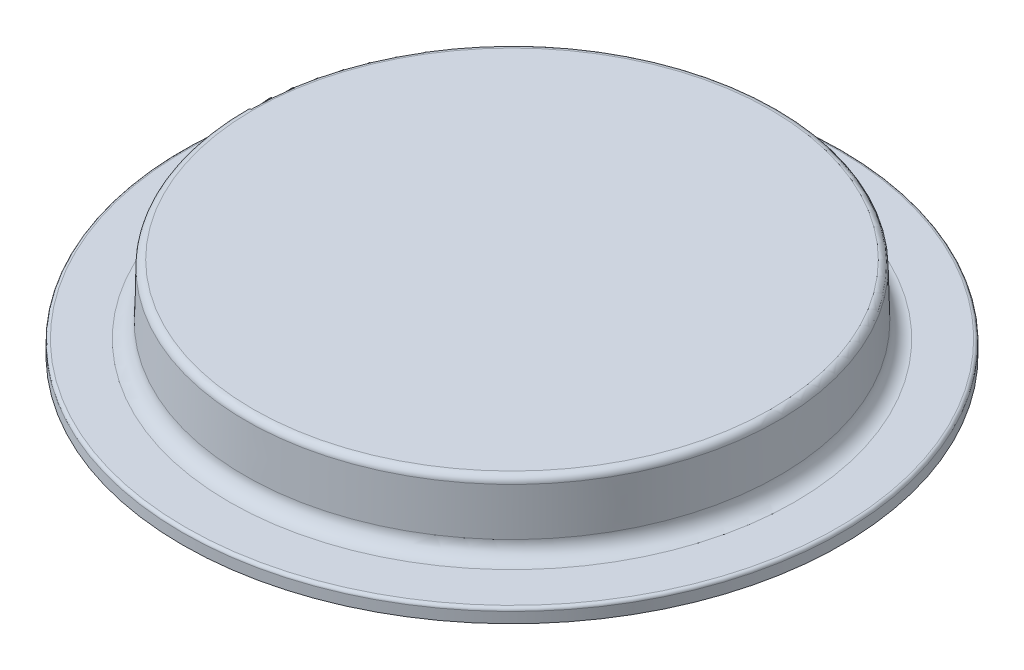
from build123d import *

# Parameters (mm, degrees)
FILLET1_R = 0.298588597
FILLET2_R = 0.059717719


with BuildPart() as part:
    # Sketch2 → Revolve1 (revolve)
    with BuildSketch(Plane(origin=(0, 0, 0), x_dir=(0, 0, -1), z_dir=(1, 0, 0))):
        with BuildLine():
            Line((-6.35, -0.79375), (-6.35, -0.529166667))
            Line((-6.35, -0.529166667), (-5.155645611, -0.529166667))
            Line((-5.155645611, -0.529166667), (-5.124404304, 0.663890696))
            ThreePointArc((-5.124404304, 0.663890696), (-5.084150358, 0.755918864), (-4.9911, 0.79375))
            Line((-4.9911, 0.79375), (0, 0.79375))
            Line((0, 0.79375), (0, -0.79375))
            Line((0, -0.79375), (-6.35, -0.79375))
        make_face()
    revolve(axis=Axis((0, -0.79375, 0), (0, 1, 0)))

    # Fillet1
    fillet1_edges = [part.edges().sort_by_distance(p)[0] for p in [
        (0, -0.529166667, -5.155645611),
    ]]
    fillet(fillet1_edges, radius=FILLET1_R)

    # Fillet2
    fillet2_edges = [part.edges().sort_by_distance(p)[0] for p in [
        (0, -0.529166667, -6.35),
    ]]
    fillet(fillet2_edges, radius=FILLET2_R)


solid = part.part
